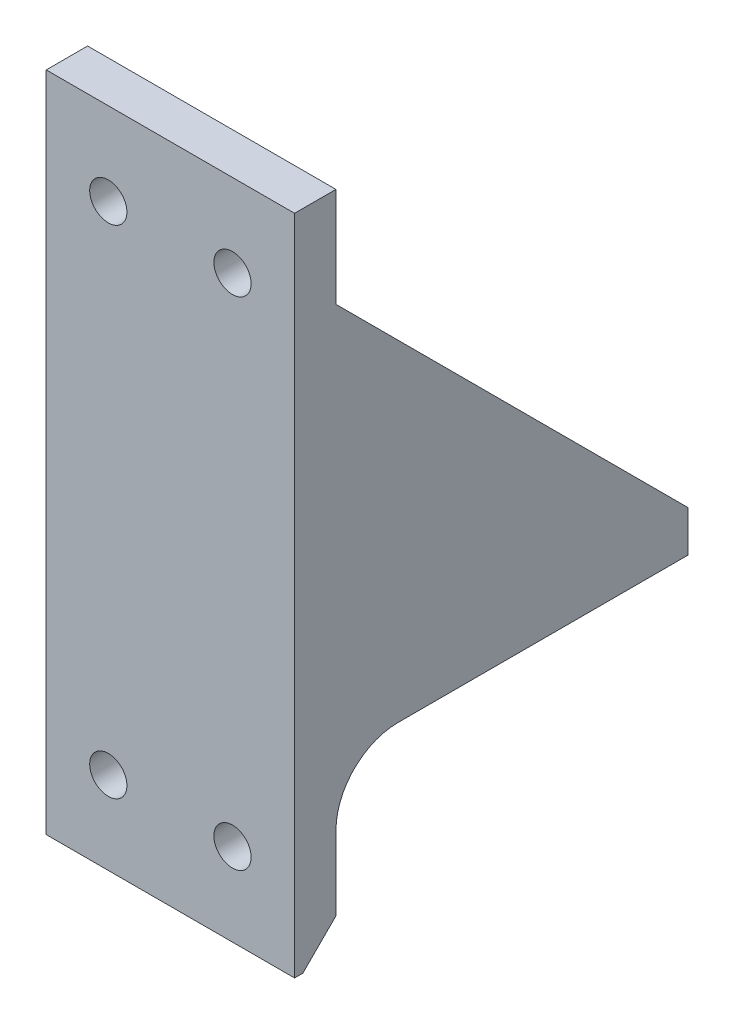
from build123d import *

# Parameters (mm, degrees)
SKETCH1_W                       = 60
SKETCH1_H                       = 160
BOSS_EXTRUDE1_DEPTH             = 10
BOSS_EXTRUDE2_REACH             = 32
BOSS_EXTRUDE2_DIRECTION_2_REACH = 32
CUT_EXTRUDE1_REACH              = 121.048
SKETCH3_R                       = 2.38
CHAMFER1_SIZE                   = 8
CUT_EXTRUDE2_REACH              = 12
SKETCH4_R                       = 4.5
SKETCH5_R                       = 7.5
CUT_EXTRUDE4_DEPTH              = 114.048
SKETCH6_R                       = 7.5
CUT_EXTRUDE5_DEPTH              = 5
FILLET1_R                       = 15


with BuildPart() as part:
    # Sketch1 → Boss-Extrude1 (new body)
    with BuildSketch(Plane.XY):
        Rectangle(SKETCH1_W, SKETCH1_H)
    extrude(amount=BOSS_EXTRUDE1_DEPTH)

    # Boss-Extrude2: up to this face of the body (flat: up to its plane)
    boss_extrude2_end = Plane(part.part.faces().sort_by_distance((30, 0, 5))[0])
    # Sketch2 → Boss-Extrude2 (add, up to the picked face)
    with BuildSketch(Plane(origin=(0, 0, 0), x_dir=(0, 0, -1), z_dir=(1, 0, 0)), mode=Mode.PRIVATE) as boss_extrude2_sk1:
        Polygon((0, -29.048), (0, -39.048), (85, -39.048), (85, -29.048), (0, 55.952), align=None)
    boss_extrude2_tool1 = split(extrude(boss_extrude2_sk1.sketch, amount=BOSS_EXTRUDE2_REACH, mode=Mode.PRIVATE), bisect_by=boss_extrude2_end, keep=Keep.BOTH, mode=Mode.PRIVATE)
    add(boss_extrude2_tool1.solids().sort_by_distance((0, -7.063873, -31.031746))[0])

    # Boss-Extrude2 direction 2: up to this face of the body (flat: up to its plane)
    boss_extrude2_direction_2_end = Plane(part.part.faces().sort_by_distance((-30, 0, 5))[0])
    # Sketch2 → Boss-Extrude2 direction 2 (add, up to the picked face)
    with BuildSketch(Plane(origin=(0, 0, 0), x_dir=(0, 0, -1), z_dir=(1, 0, 0)), mode=Mode.PRIVATE) as boss_extrude2_direction_2_sk1:
        Polygon((0, -29.048), (0, -39.048), (85, -39.048), (85, -29.048), (0, 55.952), align=None)
    boss_extrude2_direction_2_tool1 = split(extrude(boss_extrude2_direction_2_sk1.sketch, amount=-BOSS_EXTRUDE2_DIRECTION_2_REACH, mode=Mode.PRIVATE), bisect_by=boss_extrude2_direction_2_end, keep=Keep.BOTH, mode=Mode.PRIVATE)
    add(boss_extrude2_direction_2_tool1.solids().sort_by_distance((0, -7.063873, -31.031746))[0])

    # Sketch3 → Cut-Extrude1 (cut, up to next)
    with BuildSketch(Plane.XZ.offset(39.048), mode=Mode.PRIVATE) as cut_extrude1_sk1:
        with Locations((-10.31875, -34.75625)):
            Circle(SKETCH3_R)
    cut_extrude1_tool1 = extrude(cut_extrude1_sk1.sketch, amount=-CUT_EXTRUDE1_REACH, mode=Mode.PRIVATE) & part.part
    add(cut_extrude1_tool1.solids().sort_by_distance((-10.31875, -39.048, -34.75625))[0], mode=Mode.SUBTRACT)
    # Sketch3 → Cut-Extrude1 (cut, up to next)
    with BuildSketch(Plane.XZ.offset(39.048), mode=Mode.PRIVATE) as cut_extrude1_sk2:
        with Locations((10.31875, -34.75625)):
            Circle(SKETCH3_R)
    cut_extrude1_tool2 = extrude(cut_extrude1_sk2.sketch, amount=-CUT_EXTRUDE1_REACH, mode=Mode.PRIVATE) & part.part
    add(cut_extrude1_tool2.solids().sort_by_distance((10.31875, -39.048, -34.75625))[0], mode=Mode.SUBTRACT)
    # Sketch3 → Cut-Extrude1 (cut, up to next)
    with BuildSketch(Plane.XZ.offset(39.048), mode=Mode.PRIVATE) as cut_extrude1_sk3:
        with Locations((10.31875, -74.44375)):
            Circle(SKETCH3_R)
    cut_extrude1_tool3 = extrude(cut_extrude1_sk3.sketch, amount=-CUT_EXTRUDE1_REACH, mode=Mode.PRIVATE) & part.part
    add(cut_extrude1_tool3.solids().sort_by_distance((10.31875, -39.048, -74.44375))[0], mode=Mode.SUBTRACT)
    # Sketch3 → Cut-Extrude1 (cut, up to next)
    with BuildSketch(Plane.XZ.offset(39.048), mode=Mode.PRIVATE) as cut_extrude1_sk4:
        with Locations((-10.31875, -74.44375)):
            Circle(SKETCH3_R)
    cut_extrude1_tool4 = extrude(cut_extrude1_sk4.sketch, amount=-CUT_EXTRUDE1_REACH, mode=Mode.PRIVATE) & part.part
    add(cut_extrude1_tool4.solids().sort_by_distance((-10.31875, -39.048, -74.44375))[0], mode=Mode.SUBTRACT)

    # Chamfer1
    chamfer1_edges = [part.edges().sort_by_distance(p)[0] for p in [
        (0, -80, 0),
    ]]
    chamfer(chamfer1_edges, length=CHAMFER1_SIZE)

    # Sketch4 → Cut-Extrude2 (cut, up to next)
    with BuildSketch(Plane(origin=(0, 0, 0), x_dir=(-1, 0, 0), z_dir=(0, 0, -1)), mode=Mode.PRIVATE) as cut_extrude2_sk1:
        with Locations((-15, -60)):
            Circle(SKETCH4_R)
    cut_extrude2_tool1 = extrude(cut_extrude2_sk1.sketch, amount=-CUT_EXTRUDE2_REACH, mode=Mode.PRIVATE) & part.part
    add(cut_extrude2_tool1.solids().sort_by_distance((15, -60, 0))[0], mode=Mode.SUBTRACT)
    # Sketch4 → Cut-Extrude2 (cut, up to next)
    with BuildSketch(Plane(origin=(0, 0, 0), x_dir=(-1, 0, 0), z_dir=(0, 0, -1)), mode=Mode.PRIVATE) as cut_extrude2_sk2:
        with Locations((15, -60)):
            Circle(SKETCH4_R)
    cut_extrude2_tool2 = extrude(cut_extrude2_sk2.sketch, amount=-CUT_EXTRUDE2_REACH, mode=Mode.PRIVATE) & part.part
    add(cut_extrude2_tool2.solids().sort_by_distance((-15, -60, 0))[0], mode=Mode.SUBTRACT)
    # Sketch4 → Cut-Extrude2 (cut, up to next)
    with BuildSketch(Plane(origin=(0, 0, 0), x_dir=(-1, 0, 0), z_dir=(0, 0, -1)), mode=Mode.PRIVATE) as cut_extrude2_sk3:
        with Locations((-15, 60)):
            Circle(SKETCH4_R)
    cut_extrude2_tool3 = extrude(cut_extrude2_sk3.sketch, amount=-CUT_EXTRUDE2_REACH, mode=Mode.PRIVATE) & part.part
    add(cut_extrude2_tool3.solids().sort_by_distance((15, 60, 0))[0], mode=Mode.SUBTRACT)
    # Sketch4 → Cut-Extrude2 (cut, up to next)
    with BuildSketch(Plane(origin=(0, 0, 0), x_dir=(-1, 0, 0), z_dir=(0, 0, -1)), mode=Mode.PRIVATE) as cut_extrude2_sk4:
        with Locations((15, 60)):
            Circle(SKETCH4_R)
    cut_extrude2_tool4 = extrude(cut_extrude2_sk4.sketch, amount=-CUT_EXTRUDE2_REACH, mode=Mode.PRIVATE) & part.part
    add(cut_extrude2_tool4.solids().sort_by_distance((-15, 60, 0))[0], mode=Mode.SUBTRACT)

    # Sketch5 → Cut-Extrude4 (cut)
    with BuildSketch(Plane(origin=(0, 80, 0), x_dir=(1, 0, 0), z_dir=(0, 1, 0))):
        with Locations((-10.31875, 74.44375)):
            Circle(SKETCH5_R)
        with Locations((10.31875, 74.44375)):
            Circle(SKETCH5_R)
        with Locations((-10.31875, 34.75625)):
            Circle(SKETCH5_R)
        with Locations((10.31875, 34.75625)):
            Circle(SKETCH5_R)
    extrude(amount=-CUT_EXTRUDE4_DEPTH, mode=Mode.SUBTRACT)

    # Sketch6 → Cut-Extrude5 (cut)
    with BuildSketch(Plane(origin=(0, 0, 0), x_dir=(-1, 0, 0), z_dir=(0, 0, -1))):
        with Locations((-15, 60)):
            Circle(SKETCH6_R)
        with Locations((15, 60)):
            Circle(SKETCH6_R)
    extrude(amount=CUT_EXTRUDE5_DEPTH, mode=Mode.SUBTRACT)

    # Fillet1
    fillet1_edges = [part.edges().sort_by_distance(p)[0] for p in [
        (0, -39.048, 0),
    ]]
    fillet(fillet1_edges, radius=FILLET1_R)


solid = part.part
